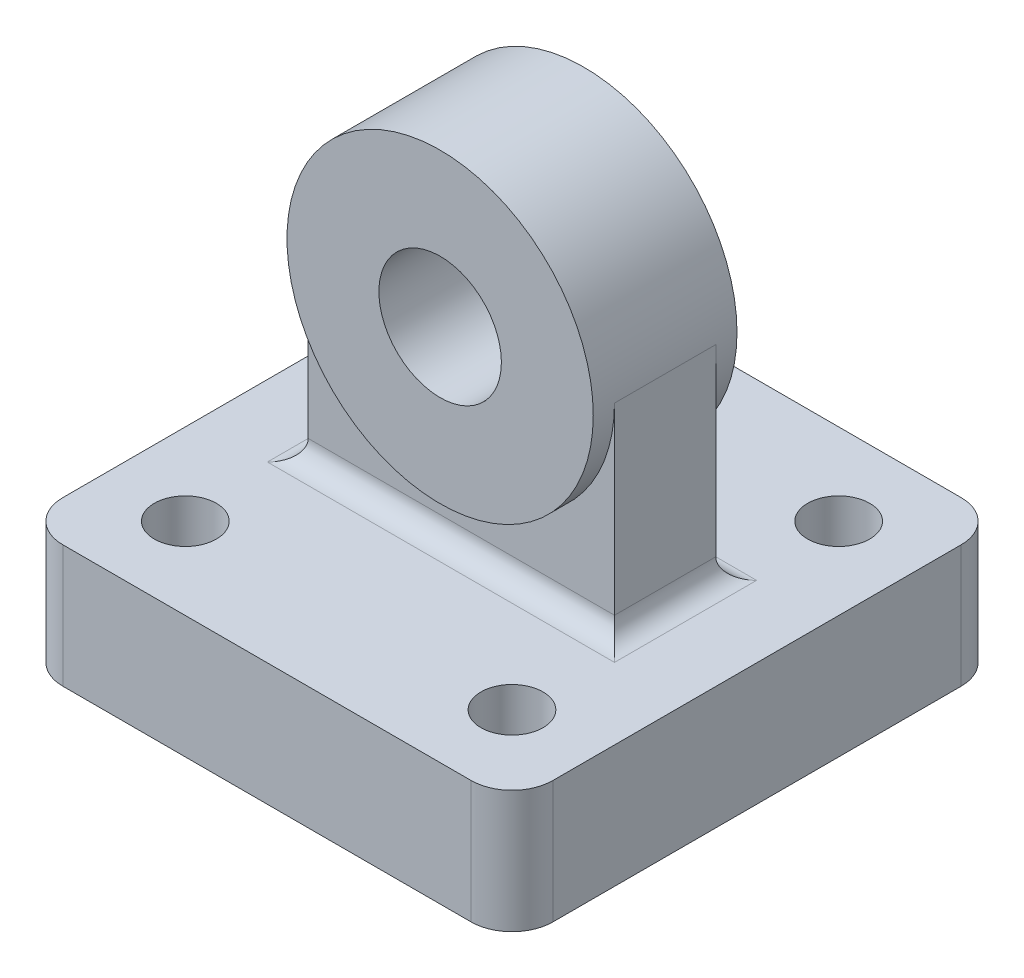
from build123d import *

# Parameters (mm, degrees)
SKETCH1_W           = 76.2
SKETCH1_H           = 76.2
SKETCH1_R           = 4.826
BOSS_EXTRUDE1_DEPTH = 19.05
BOSS_EXTRUDE4_DEPTH = 7.874
SKETCH2_5_R         = 9.525
BOSS_EXTRUDE5_DEPTH = 11.176
FILLET1_R           = 3.175
FILLET2_R           = 6.35


with BuildPart() as part:
    # Sketch1 → Boss-Extrude1 (new body)
    with BuildSketch(Plane(origin=(0, 0, 0), x_dir=(1, 0, 0), z_dir=(0, 1, 0))):
        with Locations((38.1, -38.1)):
            Rectangle(SKETCH1_W, SKETCH1_H)
        with Locations((63.5, -63.5)):
            Circle(SKETCH1_R, mode=Mode.SUBTRACT)
        with Locations((12.7, -63.5)):
            Circle(SKETCH1_R, mode=Mode.SUBTRACT)
        with Locations((63.5, -12.7)):
            Circle(SKETCH1_R, mode=Mode.SUBTRACT)
        with Locations((12.7, -12.7)):
            Circle(SKETCH1_R, mode=Mode.SUBTRACT)
    extrude(amount=BOSS_EXTRUDE1_DEPTH)

    # Sketch2 → Boss-Extrude4 (add, symmetric)
    with BuildSketch(Plane.XY.offset(38.1)):
        with BuildLine():
            ThreePointArc((61.9125, 50.8), (38.1, 26.9875), (14.2875, 50.8))
            Line((14.2875, 50.8), (14.2875, 19.05))
            Line((14.2875, 19.05), (61.9125, 19.05))
            Line((61.9125, 19.05), (61.9125, 50.8))
        make_face()
    extrude(amount=BOSS_EXTRUDE4_DEPTH, both=True)

    # Sketch2_5 → Boss-Extrude5 (add, symmetric)
    with BuildSketch(Plane.XY.offset(38.1)):
        with BuildLine():
            ThreePointArc((61.9125, 50.8), (38.1, 74.6125), (14.2875, 50.8))
            ThreePointArc((14.2875, 50.8), (38.1, 26.9875), (61.9125, 50.8))
        make_face()
        with Locations((38.1, 50.8)):
            Circle(SKETCH2_5_R, mode=Mode.SUBTRACT)
    extrude(amount=BOSS_EXTRUDE5_DEPTH, both=True)

    # Fillet1
    fillet1_edges = [part.edges().sort_by_distance(p)[0] for p in [
        (38.1, 19.05, 30.226),
        (14.2875, 19.05, 38.1),
        (38.1, 19.05, 45.974),
        (61.9125, 19.05, 38.1),
    ]]
    fillet(fillet1_edges, radius=FILLET1_R)

    # Fillet2
    fillet2_edges = [part.edges().sort_by_distance(p)[0] for p in [
        (76.2, 9.525, 76.2),
        (0, 9.525, 76.2),
        (76.2, 9.525, 0),
        (0, 9.525, 0),
    ]]
    fillet(fillet2_edges, radius=FILLET2_R)


solid = part.part
